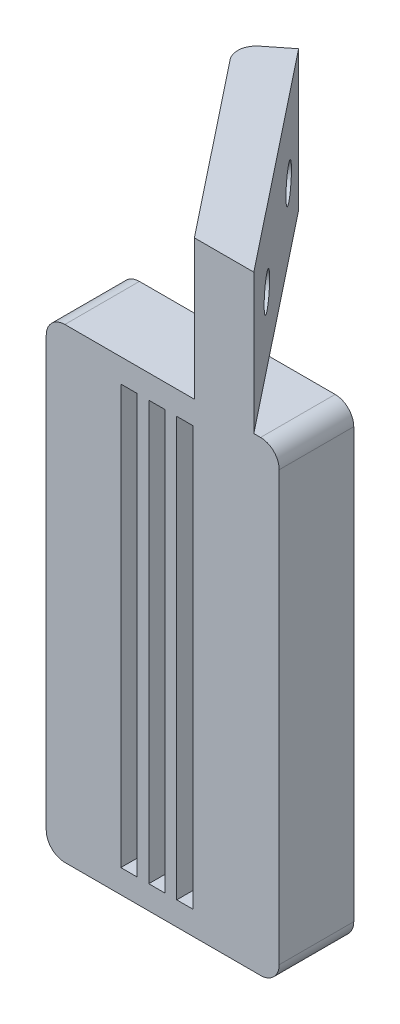
from build123d import *

# Parameters (mm, degrees)
SKETCH1_W                = 25
SKETCH1_H                = 50
BOSS_EXTRUDE1_DEPTH      = 8
BOSS_EXTRUDE1_DEPTH_BACK = 20
BOSS_EXTRUDE8_DEPTH      = 15
SKETCH4_W                = 25
SKETCH4_H                = 50
CUT_EXTRUDE1_DEPTH       = 20
SKETCH5_R                = 1.8
CUT_EXTRUDE2_DEPTH       = 18
CHAMFER1_SIZE            = 1
SKETCH6_W                = 1.735044521
SKETCH6_H                = 44.937653094
CUT_EXTRUDE3_DEPTH       = 2
SKETCH7_W                = 1.735044521
SKETCH7_H                = 44.937653094
CUT_EXTRUDE4_DEPTH       = 7
FILLET1_R                = 2


with BuildPart() as part:
    # Sketch1 → Boss-Extrude1 (new body, two sides)
    with BuildSketch(Plane.XY) as boss_extrude1_sk:
        with Locations((-12.5, 25)):
            Rectangle(SKETCH1_W, SKETCH1_H)
    extrude(amount=BOSS_EXTRUDE1_DEPTH)
    extrude(boss_extrude1_sk.sketch, amount=-BOSS_EXTRUDE1_DEPTH_BACK)

    # Sketch2 → Boss-Extrude8 (add)
    with BuildSketch(Plane(origin=(0, 50, 0), x_dir=(1, 0, 0), z_dir=(0, 1, 0))):
        Polygon((-23.57342544, 10.261766997), (-20.546166846, 6.441485314), (-9.102479138, -8), (-2.722969525, -8), (-5.256681847, -4.802554367), (-19.654628931, 13.367090477), (-21.081203491, 15.167371652), (-25, 12.062048171), align=None)
    extrude(amount=BOSS_EXTRUDE8_DEPTH)

    # Sketch4 → Cut-Extrude1 (cut)
    with BuildSketch(Plane(origin=(0, 0, -20), x_dir=(-1, 0, 0), z_dir=(0, 0, -1))):
        with Locations((12.5, 25)):
            Rectangle(SKETCH4_W, SKETCH4_H)
    extrude(amount=-CUT_EXTRUDE1_DEPTH, mode=Mode.SUBTRACT)

    # Sketch5 → Cut-Extrude2 (cut)
    with BuildSketch(Plane(origin=(-9.485580396, 0, 7.51654123), x_dir=(0.621064696, 0, 0.783759302), z_dir=(-0.783759302, 0, 0.621064696))):
        with Locations((-18.417335342, 57.115576076)):
            Circle(SKETCH5_R)
        with Locations((-4.030530081, 57.115576076)):
            Circle(SKETCH5_R)
    extrude(amount=-CUT_EXTRUDE2_DEPTH, mode=Mode.SUBTRACT)

    # Chamfer1
    chamfer1_edges = [part.edges().sort_by_distance(p)[0] for p in [
        (-22.041853627, 57.115576076, -8.328983403),
        (-13.106716789, 57.115576076, 2.946809044),
    ]]
    chamfer(chamfer1_edges, length=CHAMFER1_SIZE)

    # Sketch6 → Cut-Extrude3 (cut)
    with BuildSketch(Plane(origin=(0, 0, 0), x_dir=(-1, 0, 0), z_dir=(0, 0, -1))):
        with Locations((19.129497091, 24.995932447)):
            Rectangle(SKETCH6_W, SKETCH6_H)
        with Locations((22.129497091, 24.995932447)):
            Rectangle(SKETCH6_W, SKETCH6_H)
        with Locations((16.129497092, 24.995932447)):
            Rectangle(SKETCH6_W, SKETCH6_H)
        with Locations((13.129497092, 24.995932447)):
            Rectangle(SKETCH6_W, SKETCH6_H)
        with Locations((10.129497091, 24.995932447)):
            Rectangle(SKETCH6_W, SKETCH6_H)
        with Locations((7.129497092, 24.995932447)):
            Rectangle(SKETCH6_W, SKETCH6_H)
        with Locations((4.129497092, 24.995932447)):
            Rectangle(SKETCH6_W, SKETCH6_H)
    extrude(amount=-CUT_EXTRUDE3_DEPTH, mode=Mode.SUBTRACT)

    # Sketch7 → Cut-Extrude4 (cut, through all)
    with BuildSketch(Plane(origin=(0, 0, 2), x_dir=(-1, 0, 0), z_dir=(0, 0, -1))):
        with Locations((16.129497092, 24.995932447)):
            Rectangle(SKETCH7_W, SKETCH7_H)
        with Locations((13.129497092, 24.995932447)):
            Rectangle(SKETCH7_W, SKETCH7_H)
        with Locations((10.129497091, 24.995932447)):
            Rectangle(SKETCH7_W, SKETCH7_H)
    extrude(amount=-CUT_EXTRUDE4_DEPTH, mode=Mode.SUBTRACT)

    # Fillet1
    fillet1_edges = [part.edges().sort_by_distance(p)[0] for p in [
        (-25, 57.5, -12.062048171),
        (0, 0, 4),
        (-25, 0, 4),
        (0, 50, 4),
        (-25, 50, 4),
    ]]
    fillet(fillet1_edges, radius=FILLET1_R)


solid = part.part
